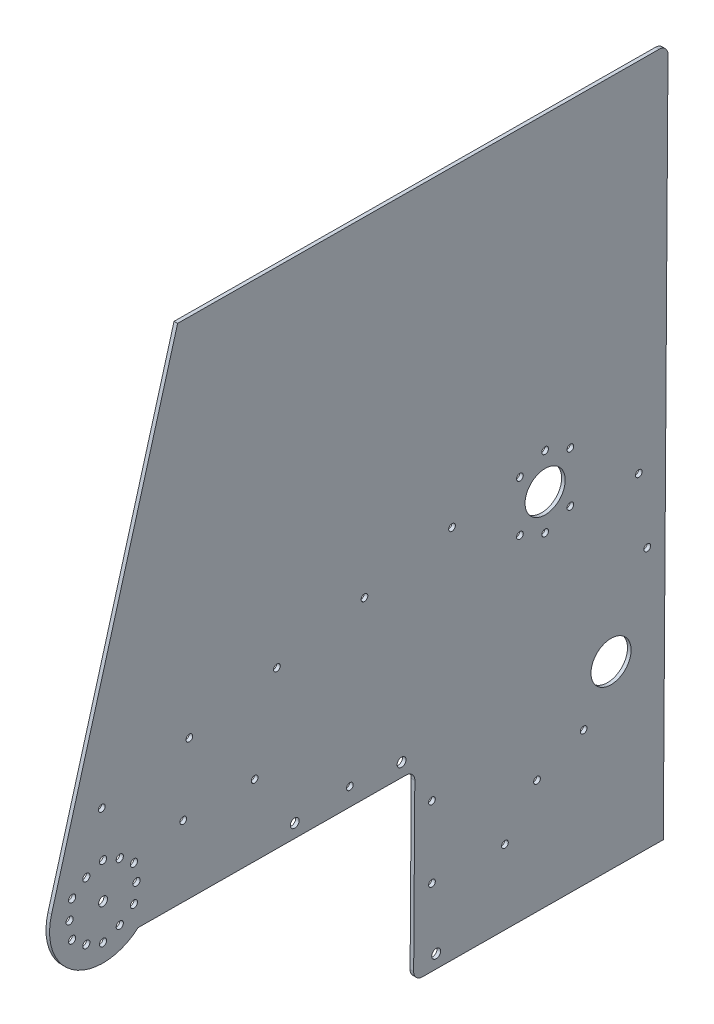
from build123d import *

# Parameters (mm, degrees)
SKETCH1_R           = 3.175
BOSS_EXTRUDE1_DEPTH = 2.54
SKETCH2_R           = 2.38125
CUT_EXTRUDE1_DEPTH  = 3.54
SKETCH5_R           = 2.5527
CUT_EXTRUDE2_DEPTH  = 3.54
SKETCH6_R           = 2.38125
SKETCH6_R_2         = 14.1605
CUT_EXTRUDE3_DEPTH  = 3.54
SKETCH7_R           = 14.1605
SKETCH7_R_2         = 2.38125
BOSS_EXTRUDE2_DEPTH = 2.54
SKETCH8_R           = 14.2875
CUT_EXTRUDE4_DEPTH  = 3.54


with BuildPart() as part:
    # Sketch1 → Boss-Extrude1 (new body)
    with BuildSketch(Plane(origin=(2097.33945945, 0, 0), x_dir=(0, 0, -1), z_dir=(1, 0, 0))):
        with BuildLine():
            Line((470.462593133, 294.283973481), (380.69060226, -25.250155611))
            ThreePointArc((380.69060226, -25.250155611), (396.988966218, -67.7453513), (442.372216694, -64.304580962))
            Line((442.372216694, -64.304580962), (633.066836095, -65.629031002))
            ThreePointArc((633.066836095, -65.629031002), (637.543938621, -67.520043059), (639.372580729, -72.022980064))
            Line((639.372580729, -72.022980064), (638.556689771, -189.495146754))
            ThreePointArc((638.556689771, -189.495146754), (640.385331878, -193.998083759), (644.862434405, -195.889095816))
            Line((644.862434405, -195.889095816), (816.308299304, -197.079855594))
            Line((816.308299304, -197.079855594), (819.660067566, 285.508504864))
            ThreePointArc((819.660067566, 285.508504864), (817.831425459, 290.01144187), (813.354322932, 291.902453927))
            Line((813.354322932, 291.902453927), (470.462593133, 294.283973481))
        make_face()
        with Locations((553.895503221, -55.553924847)):
            Circle(SKETCH1_R, mode=Mode.SUBTRACT)
        with Locations((738.492000758, 61.775645376)):
            Circle(SKETCH1_R, mode=Mode.SUBTRACT)
        with Locations((779.099930223, -68.570323835)):
            Circle(SKETCH1_R, mode=Mode.SUBTRACT)
        with Locations((654.585392145, -186.431395895)):
            Circle(SKETCH1_R, mode=Mode.SUBTRACT)
        with Locations((417.370503221, -35.55524491)):
            Circle(SKETCH1_R, mode=Mode.SUBTRACT)
        with Locations((629.958065992, -56.082209622)):
            Circle(SKETCH1_R, mode=Mode.SUBTRACT)
    extrude(amount=BOSS_EXTRUDE1_DEPTH)

    # Sketch2 → Cut-Extrude1 (cut, through all)
    with BuildSketch(Plane(origin=(2099.87945945, 0, 0), x_dir=(0, 0, -1), z_dir=(1, 0, 0))):
        with Locations((759.618090186, -100.982485439)):
            Circle(SKETCH2_R)
        with Locations((541.187693092, 46.53204311)):
            Circle(SKETCH2_R)
        with Locations((478.851639869, 34.42970992)):
            Circle(SKETCH2_R)
        with Locations((416.515586647, 22.327376731)):
            Circle(SKETCH2_R)
        with Locations((525.320503221, -14.245042905)):
            Circle(SKETCH2_R)
        with Locations((798.886947172, 37.479390763)):
            Circle(SKETCH2_R)
        with Locations((665.859799537, 70.736709489)):
            Circle(SKETCH2_R)
        with Locations((603.523746314, 58.634376299)):
            Circle(SKETCH2_R)
        with Locations((703.559149884, -143.519538535)):
            Circle(SKETCH2_R)
        with Locations((726.384244699, -115.392244277)):
            Circle(SKETCH2_R)
        with Locations((804.898658391, -11.249556635)):
            Circle(SKETCH2_R)
        with Locations((474.520503221, -14.245042905)):
            Circle(SKETCH2_R)
        with Locations((651.589984927, -141.551336746)):
            Circle(SKETCH2_R)
        with Locations((651.589984927, -90.751336746)):
            Circle(SKETCH2_R)
        with Locations((593.128456503, -52.651336746)):
            Circle(SKETCH2_R)
    extrude(amount=-CUT_EXTRUDE1_DEPTH, mode=Mode.SUBTRACT)

    # Sketch5 → Cut-Extrude2 (cut, through all)
    with BuildSketch(Plane(origin=(2099.87945945, 0, 0), x_dir=(0, 0, -1), z_dir=(1, 0, 0))):
        with Locations((395.373457964, -48.255244909)):
            Circle(SKETCH5_R)
        with Locations((405.46425322, -56.177474835)):
            Circle(SKETCH5_R)
        with Locations((395.373457964, -22.855244907)):
            Circle(SKETCH5_R)
        with Locations((393.55800322, -35.555244908)):
            Circle(SKETCH5_R)
        with Locations((417.370503221, -10.155244906)):
            Circle(SKETCH5_R)
        with Locations((405.46425322, -14.93301498)):
            Circle(SKETCH5_R)
        with Locations((439.367548478, -22.855244907)):
            Circle(SKETCH5_R)
        with Locations((429.276753221, -14.93301498)):
            Circle(SKETCH5_R)
        with Locations((439.367548478, -48.255244909)):
            Circle(SKETCH5_R)
        with Locations((441.183003221, -35.555244908)):
            Circle(SKETCH5_R)
        with Locations((417.370503221, -60.955244909)):
            Circle(SKETCH5_R)
        with Locations((429.276753221, -56.177474835)):
            Circle(SKETCH5_R)
    extrude(amount=-CUT_EXTRUDE2_DEPTH, mode=Mode.SUBTRACT)

    # Sketch6 → Cut-Extrude3 (cut, through all)
    with BuildSketch(Plane.ZY.offset(-2099.87945945)):
        with Locations((-714.213403899, 41.676013157)):
            Circle(SKETCH6_R)
        with Locations((-714.213403899, 77.597201157)):
            Circle(SKETCH6_R)
        with Locations((-732.173834383, 85.036607157)):
            Circle(SKETCH6_R)
        with Locations((-750.134264867, 77.597201157)):
            Circle(SKETCH6_R)
        with Locations((-750.134264867, 41.676013157)):
            Circle(SKETCH6_R)
        with Locations((-732.173834383, 34.236607157)):
            Circle(SKETCH6_R)
        with Locations((-732.173834383, 59.636607157)):
            Circle(SKETCH6_R_2)
    extrude(amount=CUT_EXTRUDE3_DEPTH, mode=Mode.SUBTRACT)

    # Sketch7 → Boss-Extrude2 (add)
    with BuildSketch(Plane(origin=(2099.87945945, 0, 0), x_dir=(0, 0, -1), z_dir=(1, 0, 0))):
        with Locations((732.173834383, 59.636607157)):
            Circle(SKETCH7_R)
        with Locations((732.173834383, 59.636607157)):
            Circle(SKETCH7_R_2, mode=Mode.SUBTRACT)
    extrude(amount=-BOSS_EXTRUDE2_DEPTH)

    # Sketch8 → Cut-Extrude4 (cut, through all)
    with BuildSketch(Plane.ZY.offset(-2097.33945945)):
        with Locations((-732.173834383, 59.636607157)):
            Circle(SKETCH8_R)
        with Locations((-779.099930223, -68.570323835)):
            Circle(SKETCH8_R)
    extrude(amount=-CUT_EXTRUDE4_DEPTH, mode=Mode.SUBTRACT)


solid = part.part
